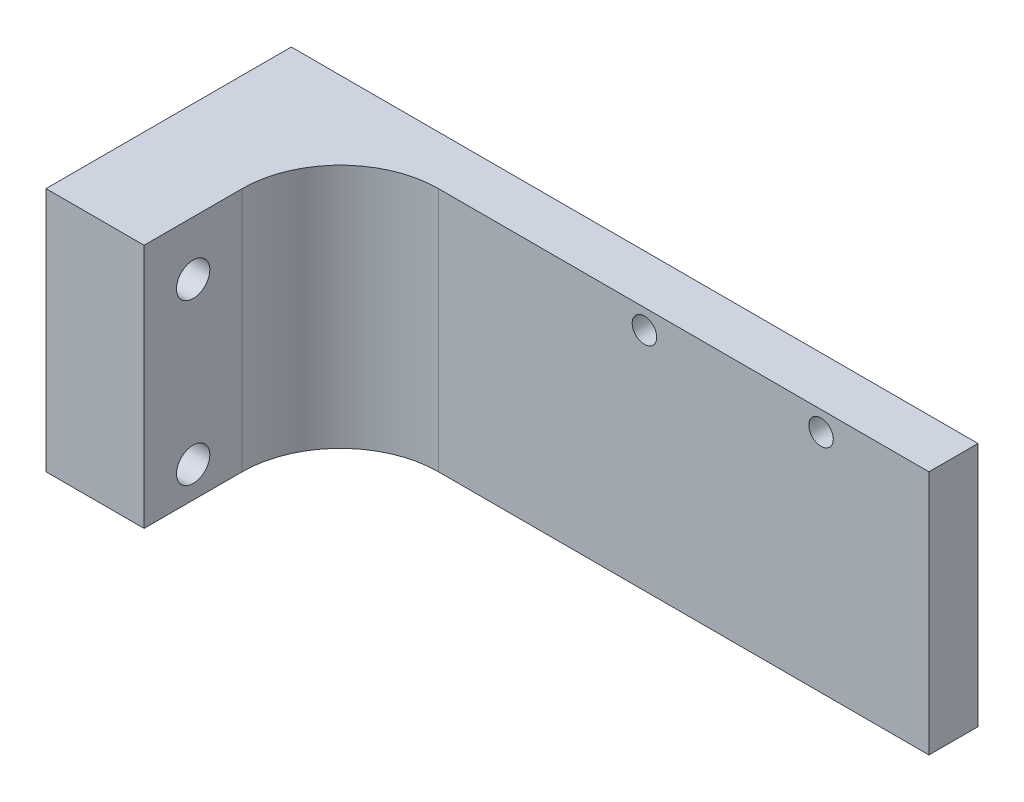
from build123d import *

# Parameters (mm, degrees)
SKETCH1_W           = 70
SKETCH1_H           = 25
BOSS_EXTRUDE1_DEPTH = 5
SKETCH2_R           = 1.25
CUT_EXTRUDE2_DEPTH  = 6
SKETCH5_W           = 10
SKETCH5_H           = 25
BOSS_EXTRUDE3_DEPTH = 20
FILLET1_R           = 10
SKETCH6_R           = 1.7
CUT_EXTRUDE3_DEPTH  = 11


with BuildPart() as part:
    # Sketch1 → Boss-Extrude1 (new body)
    with BuildSketch(Plane.XY):
        with Locations((35, -12.5)):
            Rectangle(SKETCH1_W, SKETCH1_H)
    extrude(amount=BOSS_EXTRUDE1_DEPTH)

    # Sketch2 → Cut-Extrude2 (cut, through all)
    with BuildSketch(Plane.XY.offset(5)):
        with Locations((41, -2)):
            Circle(SKETCH2_R)
        with Locations((59, -2)):
            Circle(SKETCH2_R)
    extrude(amount=-CUT_EXTRUDE2_DEPTH, mode=Mode.SUBTRACT)

    # Sketch5 → Boss-Extrude3 (add)
    with BuildSketch(Plane.XY.offset(5)):
        with Locations((5, -12.5)):
            Rectangle(SKETCH5_W, SKETCH5_H)
    extrude(amount=BOSS_EXTRUDE3_DEPTH)

    # Fillet1
    fillet1_edges = [part.edges().sort_by_distance(p)[0] for p in [
        (10, -12.5, 5),
    ]]
    fillet(fillet1_edges, radius=FILLET1_R)

    # Sketch6 → Cut-Extrude3 (cut, through all)
    with BuildSketch(Plane(origin=(10, 0, 0), x_dir=(0, 0, -1), z_dir=(1, 0, 0))):
        with Locations((-20, -21.834919238)):
            Circle(SKETCH6_R)
        with Locations((-20, -5.503108416)):
            Circle(SKETCH6_R)
    extrude(amount=-CUT_EXTRUDE3_DEPTH, mode=Mode.SUBTRACT)


solid = part.part
